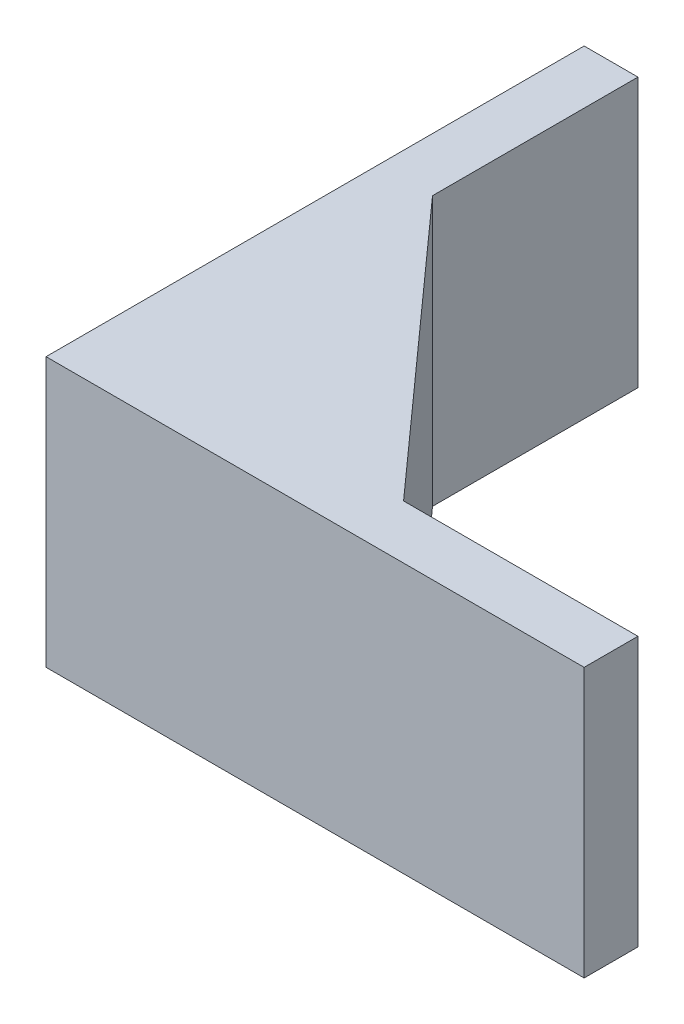
from build123d import *

# Parameters (mm, degrees)
EXTRUDE_1_DEPTH = 20


with BuildPart() as part:
    # 草图1 → 凸台-拉伸1 (new body)
    with BuildSketch(Plane(origin=(0, 0, 0), x_dir=(1, 0, 0), z_dir=(0, 1, 0))):
        Polygon((0, 40), (0, 0), (40, 0), (40, 4), (22.576549518, 4), (4, 24.728267981), (4, 40), align=None)
    extrude(amount=EXTRUDE_1_DEPTH)


solid = part.part
